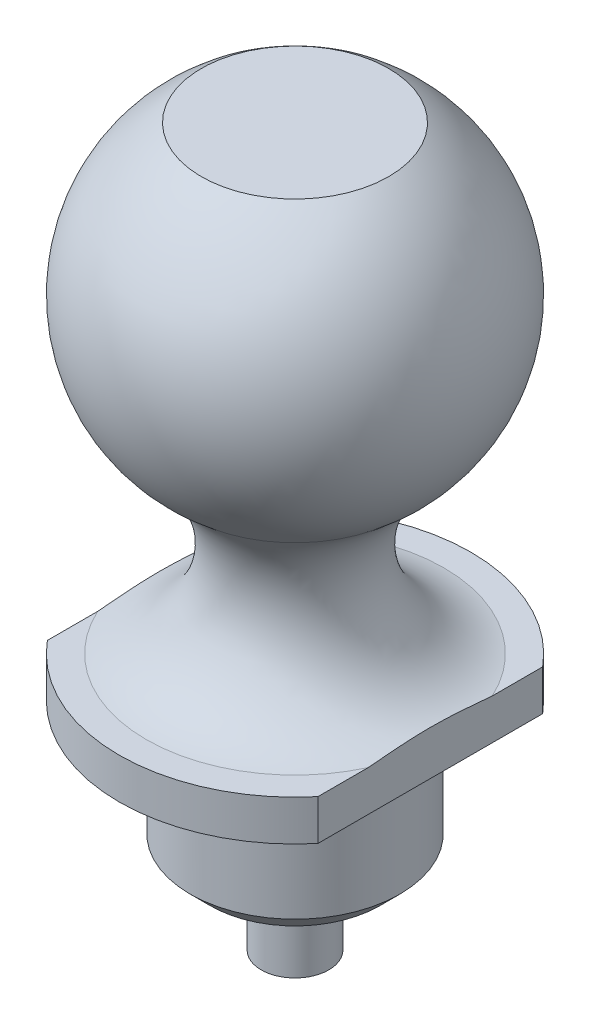
from build123d import *

# Parameters (mm, degrees)
CUT_EXTRUDE4_DEPTH      = 5
CROQUIS1_R              = 1.25
SALIENTE_EXTRUIR1_DEPTH = 3
CROQUIS2_R              = 5
CROQUIS2_R_2            = 3.875
CORTAR_EXTRUIR2_DEPTH   = 5


with BuildPart() as part:
    # Sketch1 → Revolve1 (revolve)
    with BuildSketch(Plane.XY):
        with BuildLine():
            Line((4.304738622, -13), (4.304738622, -16.832856763))
            Line((4.304738622, -16.832856763), (3.137595386, -18))
            Line((3.137595386, -18), (0, -18))
            Line((0, -18), (0, -13))
            Line((0, -13), (0, 0))
            Line((0, 0), (0, 5.5))
            Line((0, 5.5), (3.464101615, 5.5))
            ThreePointArc((3.464101615, 5.5), (6.492002013, 0.322350532), (3.991907406, -5.129783159))
            ThreePointArc((3.991907406, -5.129783159), (2.699987373, -8.799256044), (5.5, -11.5))
            Line((5.5, -11.5), (6.5, -11.5))
            Line((6.5, -11.5), (6.5, -13))
            Line((6.5, -13), (4.304738622, -13))
        make_face()
    revolve(axis=Axis((0, -13, 0), (0, 1, 0)))

    # Sketch5 → Cut-Extrude4 (cut)
    with BuildSketch(Plane.XZ.offset(13)):
        with BuildLine():
            Line((-5, 4.153311931), (-5, -4.153311931))
            ThreePointArc((-5, -4.153311931), (-6.5, 0), (-5, 4.153311931))
        make_face()
        with BuildLine():
            Line((5, -4.153311931), (5, 4.153311931))
            ThreePointArc((5, 4.153311931), (6.5, 0), (5, -4.153311931))
        make_face()
    extrude(amount=-CUT_EXTRUDE4_DEPTH, mode=Mode.SUBTRACT)

    # Croquis1 → Saliente-Extruir1 (add)
    with BuildSketch(Plane(origin=(0, -18, 0), x_dir=(-1, 0, 0), z_dir=(0, -1, 0))):
        Circle(CROQUIS1_R)
    extrude(amount=SALIENTE_EXTRUIR1_DEPTH)

    # Croquis2 → Cortar-Extruir2 (cut)
    with BuildSketch(Plane.XZ.offset(18)):
        Circle(CROQUIS2_R)
        Circle(CROQUIS2_R_2, mode=Mode.SUBTRACT)
    extrude(amount=-CORTAR_EXTRUIR2_DEPTH, mode=Mode.SUBTRACT)


solid = part.part
